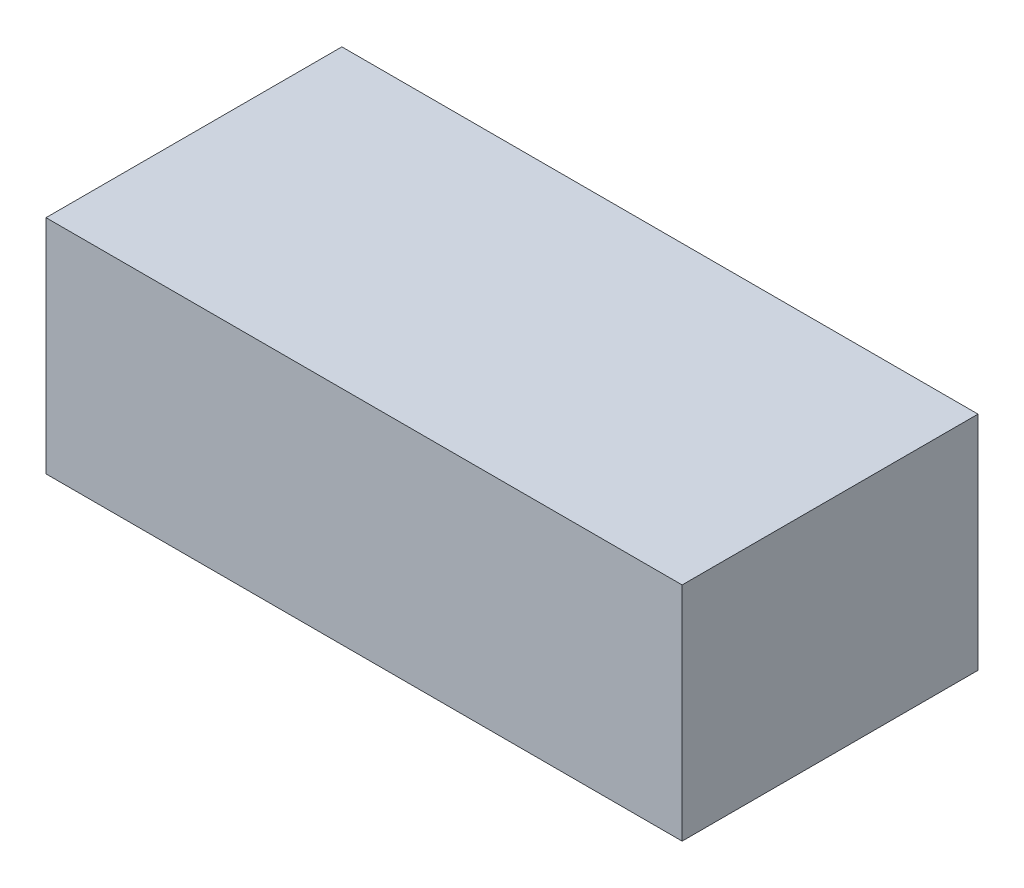
from build123d import *

# Parameters (mm, degrees)
SKETCH1_W           = 43
SKETCH1_H           = 20
BOSS_EXTRUDE1_DEPTH = 15


with BuildPart() as part:
    # Sketch1 → Boss-Extrude1 (new body)
    with BuildSketch(Plane(origin=(0, 0, 0), x_dir=(1, 0, 0), z_dir=(0, 1, 0))):
        Rectangle(SKETCH1_W, SKETCH1_H)
    extrude(amount=BOSS_EXTRUDE1_DEPTH)


solid = part.part
